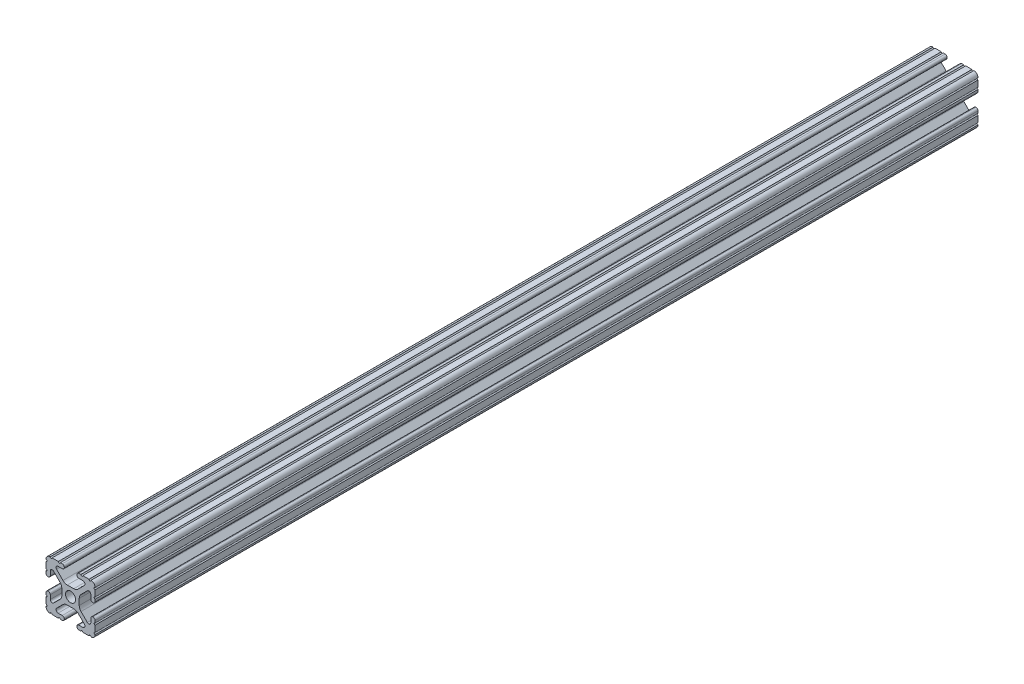
from build123d import *

# Parameters (mm, degrees)
SKETCH1_R      = 2.6035
EXTRUDE1_DEPTH = 457.2


with BuildPart() as part:
    # Sketch1 → Extrude1 (new body)
    with BuildSketch(Plane.XY):
        with BuildLine():
            Line((-7.207191475, 8.724540082), (-3.900315394, 5.423689619))
            ThreePointArc((-3.900315394, 5.423689619), (-2.8709819, 4.736928798), (-1.657299581, 4.4958))
            Line((-1.657299581, 4.4958), (1.657299581, 4.4958))
            ThreePointArc((1.657299581, 4.4958), (2.8709819, 4.736928798), (3.900315394, 5.423689619))
            Line((3.900315394, 5.423689619), (7.207191475, 8.724540082))
            ThreePointArc((7.207191475, 8.724540082), (7.43216212, 9.851515102), (6.476774195, 10.4902))
            Line((6.476774195, 10.4902), (4.2874692, 10.4902))
            ThreePointArc((4.2874692, 10.4902), (3.545700044, 10.797450844), (3.2384492, 11.53922))
            Line((3.2384492, 11.53922), (3.2384492, 11.65098))
            ThreePointArc((3.2384492, 11.65098), (3.545700044, 12.392749156), (4.2874692, 12.7))
            Line((4.2874692, 12.7), (5.3170836, 12.7))
            ThreePointArc((5.3170836, 12.7), (5.8250836, 12.192), (6.3330836, 12.7))
            Line((6.3330836, 12.7), (9.5504, 12.7))
            ThreePointArc((9.5504, 12.7), (10.058323491, 12.192000006), (10.566399977, 12.699846982))
            ThreePointArc((10.566399977, 12.699846982), (12.082522516, 12.082522516), (12.699846982, 10.566399977))
            ThreePointArc((12.699846982, 10.566399977), (12.192000006, 10.058323491), (12.7, 9.5504))
            Line((12.7, 9.5504), (12.7, 6.3331344))
            ThreePointArc((12.7, 6.3331344), (12.192, 5.8251344), (12.7, 5.3171344))
            Line((12.7, 5.3171344), (12.7, 4.287470133))
            ThreePointArc((12.7, 4.287470133), (12.392749156, 3.545700977), (11.65098, 3.238450133))
            Line((11.65098, 3.238450133), (11.53922, 3.238450133))
            ThreePointArc((11.53922, 3.238450133), (10.797450844, 3.545700977), (10.4902, 4.287470133))
            Line((10.4902, 4.287470133), (10.4902, 6.402089023))
            ThreePointArc((10.4902, 6.402089023), (9.856394933, 7.351113629), (8.736962546, 7.129240479))
            Line((8.736962546, 7.129240479), (5.440484187, 3.838768792))
            ThreePointArc((5.440484187, 3.838768792), (4.75073678, 2.808015636), (4.5085, 1.591658411))
            Line((4.5085, 1.591658411), (4.5085, -1.591658411))
            ThreePointArc((4.5085, -1.591658411), (4.75073678, -2.808015636), (5.440484187, -3.838768792))
            Line((5.440484187, -3.838768792), (8.736962546, -7.129240479))
            ThreePointArc((8.736962546, -7.129240479), (9.856394933, -7.351113629), (10.4902, -6.402089023))
            Line((10.4902, -6.402089023), (10.4902, -4.287470133))
            ThreePointArc((10.4902, -4.287470133), (10.797450844, -3.545700977), (11.53922, -3.238450133))
            Line((11.53922, -3.238450133), (11.65098, -3.238450133))
            ThreePointArc((11.65098, -3.238450133), (12.392749156, -3.545700977), (12.7, -4.287470133))
            Line((12.7, -4.287470133), (12.7, -5.3170836))
            ThreePointArc((12.7, -5.3170836), (12.192, -5.8250836), (12.7, -6.3330836))
            Line((12.7, -6.3330836), (12.7, -9.5504))
            ThreePointArc((12.7, -9.5504), (12.192000006, -10.058323491), (12.699846982, -10.566399977))
            ThreePointArc((12.699846982, -10.566399977), (12.082522516, -12.082522516), (10.566399977, -12.699846982))
            ThreePointArc((10.566399977, -12.699846982), (10.058323491, -12.192000006), (9.5504, -12.7))
            Line((9.5504, -12.7), (6.3331344, -12.7))
            ThreePointArc((6.3331344, -12.7), (5.8251344, -12.192), (5.3171344, -12.7))
            Line((5.3171344, -12.7), (4.28752, -12.7))
            ThreePointArc((4.28752, -12.7), (3.545750844, -12.392749156), (3.2385, -11.65098))
            Line((3.2385, -11.65098), (3.2385, -11.53922))
            ThreePointArc((3.2385, -11.53922), (3.545750844, -10.797450844), (4.28752, -10.4902))
            Line((4.28752, -10.4902), (6.41641086, -10.4902))
            ThreePointArc((6.41641086, -10.4902), (7.414733441, -9.822812921), (7.179652728, -8.645192207))
            Line((7.179652728, -8.645192207), (3.95226937, -5.423689619))
            ThreePointArc((3.95226937, -5.423689619), (2.922935876, -4.736928798), (1.709253557, -4.4958))
            Line((1.709253557, -4.4958), (-1.709253557, -4.4958))
            ThreePointArc((-1.709253557, -4.4958), (-2.922935876, -4.736928798), (-3.95226937, -5.423689619))
            Line((-3.95226937, -5.423689619), (-7.179652728, -8.645192207))
            ThreePointArc((-7.179652728, -8.645192207), (-7.414733441, -9.822812921), (-6.41641086, -10.4902))
            Line((-6.41641086, -10.4902), (-4.28752, -10.4902))
            ThreePointArc((-4.28752, -10.4902), (-3.545750844, -10.797450844), (-3.2385, -11.53922))
            Line((-3.2385, -11.53922), (-3.2385, -11.65098))
            ThreePointArc((-3.2385, -11.65098), (-3.545750844, -12.392749156), (-4.28752, -12.7))
            Line((-4.28752, -12.7), (-5.3171344, -12.7))
            ThreePointArc((-5.3171344, -12.7), (-5.8251344, -12.192), (-6.3331344, -12.7))
            Line((-6.3331344, -12.7), (-9.5504, -12.7))
            ThreePointArc((-9.5504, -12.7), (-10.058323491, -12.192000006), (-10.566399977, -12.699846982))
            ThreePointArc((-10.566399977, -12.699846982), (-12.082522516, -12.082522516), (-12.699846982, -10.566399977))
            ThreePointArc((-12.699846982, -10.566399977), (-12.192000006, -10.058323491), (-12.7, -9.5504))
            Line((-12.7, -9.5504), (-12.7, -6.3330836))
            ThreePointArc((-12.7, -6.3330836), (-12.192, -5.8250836), (-12.7, -5.3170836))
            Line((-12.7, -5.3170836), (-12.7, -4.287470133))
            ThreePointArc((-12.7, -4.287470133), (-12.392749156, -3.545700977), (-11.65098, -3.238450133))
            Line((-11.65098, -3.238450133), (-11.53922, -3.238450133))
            ThreePointArc((-11.53922, -3.238450133), (-10.797450844, -3.545700977), (-10.4902, -4.287470133))
            Line((-10.4902, -4.287470133), (-10.4902, -6.402089023))
            ThreePointArc((-10.4902, -6.402089023), (-9.856394933, -7.351113629), (-8.736962546, -7.129240479))
            Line((-8.736962546, -7.129240479), (-5.440484187, -3.838768792))
            ThreePointArc((-5.440484187, -3.838768792), (-4.75073678, -2.808015636), (-4.5085, -1.591658411))
            Line((-4.5085, -1.591658411), (-4.5085, 1.591658411))
            ThreePointArc((-4.5085, 1.591658411), (-4.75073678, 2.808015636), (-5.440484187, 3.838768792))
            Line((-5.440484187, 3.838768792), (-8.736962546, 7.129240479))
            ThreePointArc((-8.736962546, 7.129240479), (-9.856394933, 7.351113629), (-10.4902, 6.402089023))
            Line((-10.4902, 6.402089023), (-10.4902, 4.287470133))
            ThreePointArc((-10.4902, 4.287470133), (-10.797450844, 3.545700977), (-11.53922, 3.238450133))
            Line((-11.53922, 3.238450133), (-11.65098, 3.238450133))
            ThreePointArc((-11.65098, 3.238450133), (-12.392749156, 3.545700977), (-12.7, 4.287470133))
            Line((-12.7, 4.287470133), (-12.7, 5.3171344))
            ThreePointArc((-12.7, 5.3171344), (-12.192, 5.8251344), (-12.7, 6.3331344))
            Line((-12.7, 6.3331344), (-12.7, 9.5504))
            ThreePointArc((-12.7, 9.5504), (-12.192000006, 10.058323491), (-12.699846982, 10.566399977))
            ThreePointArc((-12.699846982, 10.566399977), (-12.082522516, 12.082522516), (-10.566399977, 12.699846982))
            ThreePointArc((-10.566399977, 12.699846982), (-10.058323491, 12.192000006), (-9.5504, 12.7))
            Line((-9.5504, 12.7), (-6.3330836, 12.7))
            ThreePointArc((-6.3330836, 12.7), (-5.8250836, 12.192), (-5.3170836, 12.7))
            Line((-5.3170836, 12.7), (-4.2874692, 12.7))
            ThreePointArc((-4.2874692, 12.7), (-3.545700044, 12.392749156), (-3.2384492, 11.65098))
            Line((-3.2384492, 11.65098), (-3.2384492, 11.53922))
            ThreePointArc((-3.2384492, 11.53922), (-3.545700044, 10.797450844), (-4.2874692, 10.4902))
            Line((-4.2874692, 10.4902), (-6.476774195, 10.4902))
            ThreePointArc((-6.476774195, 10.4902), (-7.43216212, 9.851515102), (-7.207191475, 8.724540082))
        make_face()
        Circle(SKETCH1_R, mode=Mode.SUBTRACT)
    extrude(amount=-EXTRUDE1_DEPTH)


solid = part.part
